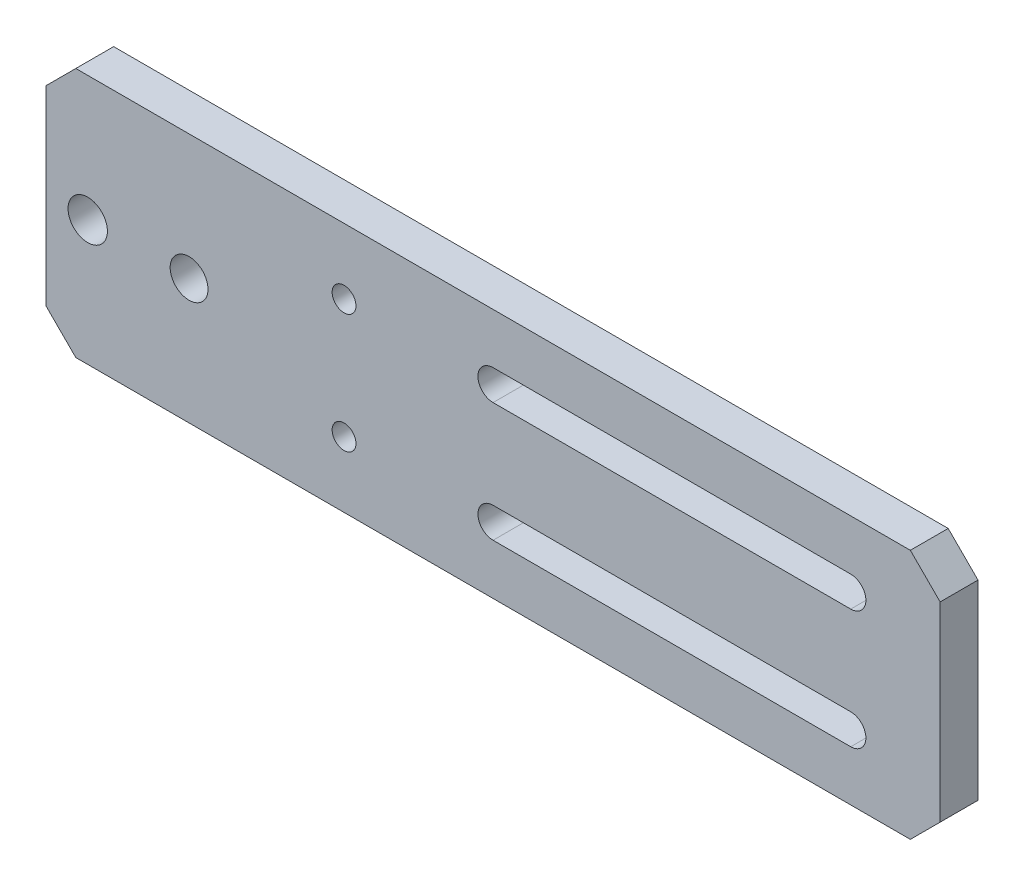
from build123d import *

# Parameters (mm, degrees)
SKETCH1_W           = 200
SKETCH1_H           = 42
BOSS_EXTRUDE1_DEPTH = 6.35
SKETCH3_R           = 2
CUT_EXTRUDE2_DEPTH  = 7.35
SKETCH4_R           = 3.175
CUT_EXTRUDE3_DEPTH  = 7.35
CHAMFER1_SIZE       = 5
SKETCH9_R           = 3.175
CUT_EXTRUDE8_DEPTH  = 7.35
SKETCH10_R          = 12.5
CUT_EXTRUDE9_DEPTH  = 7.35
SKETCH12_R          = 3.302
CUT_EXTRUDE11_DEPTH = 7.35
SKETCH13_R          = 12.5
CUT_EXTRUDE12_DEPTH = 10


with BuildPart() as part:
    # Sketch1 → Boss-Extrude1 (new body)
    with BuildSketch(Plane.XY):
        Rectangle(SKETCH1_W, SKETCH1_H)
    extrude(amount=BOSS_EXTRUDE1_DEPTH)

    # Sketch3 → Cut-Extrude2 (cut, through all)
    with BuildSketch(Plane.XY.offset(6.35)):
        with Locations((-50, 10)):
            Circle(SKETCH3_R)
        with Locations((-50, -10)):
            Circle(SKETCH3_R)
    extrude(amount=-CUT_EXTRUDE2_DEPTH, mode=Mode.SUBTRACT)

    # Sketch4 → Cut-Extrude3 (cut, through all)
    with BuildSketch(Plane.XY.offset(6.35)):
        with Locations((-76, 0)):
            Circle(SKETCH4_R)
    extrude(amount=-CUT_EXTRUDE3_DEPTH, mode=Mode.SUBTRACT)

    # Chamfer1
    chamfer1_edges = [part.edges().sort_by_distance(p)[0] for p in [
        (100, -21, 3.175),
        (-100, -21, 3.175),
        (-100, 21, 3.175),
        (100, 21, 3.175),
    ]]
    chamfer(chamfer1_edges, length=CHAMFER1_SIZE)

    # Sketch9 → Cut-Extrude8 (cut, through all)
    with BuildSketch(Plane.XY.offset(6.35)):
        with Locations((80, 0)):
            Circle(SKETCH9_R)
    extrude(amount=-CUT_EXTRUDE8_DEPTH, mode=Mode.SUBTRACT)

    # Sketch10 → Cut-Extrude9 (cut, through all)
    with BuildSketch(Plane.XY.offset(6.35)):
        with Locations((80, 0)):
            Circle(SKETCH10_R)
    extrude(amount=-CUT_EXTRUDE9_DEPTH, mode=Mode.SUBTRACT)

    # Sketch12 → Cut-Extrude11 (cut, through all)
    with BuildSketch(Plane.XY.offset(6.35)):
        with Locations((-93, 0)):
            Circle(SKETCH12_R)
    extrude(amount=-CUT_EXTRUDE11_DEPTH, mode=Mode.SUBTRACT)

    # Sketch13 → Cut-Extrude12 (cut)
    with BuildSketch(Plane.XY.offset(6.35)):
        Polygon((45, 21), (50, 16), (50, -16), (45, -21), (95, -21), (100, -16), (100, 16), (95, 21), align=None)
        with Locations((80, 0)):
            Circle(SKETCH13_R, mode=Mode.SUBTRACT)
        with BuildLine():
            Line((-25, 7.46), (35, 7.46))
            ThreePointArc((35, 7.46), (37.54, 10), (35, 12.54))
            Line((35, 12.54), (-25, 12.54))
            ThreePointArc((-25, 12.54), (-27.54, 10), (-25, 7.46))
        make_face()
        with BuildLine():
            ThreePointArc((35, -7.46), (37.54, -10), (35, -12.54))
            Line((35, -12.54), (-25, -12.54))
            ThreePointArc((-25, -12.54), (-27.54, -10), (-25, -7.46))
            Line((-25, -7.46), (35, -7.46))
        make_face()
    extrude(amount=-CUT_EXTRUDE12_DEPTH, mode=Mode.SUBTRACT)


solid = part.part
